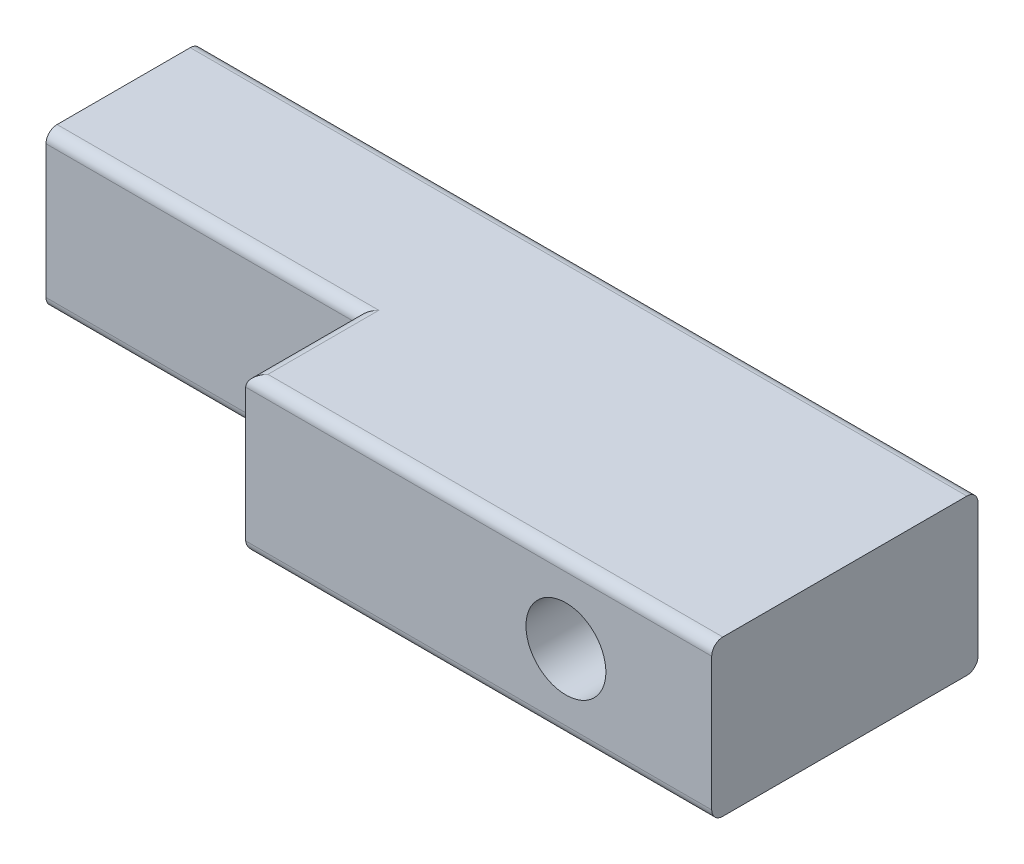
from build123d import *

# Parameters (mm, degrees)
SKETCH1_W                  = 35
SKETCH1_H                  = 7
BOSS_EXTRUDE1_DEPTH        = 7
SKETCH3_W                  = 21
SKETCH3_H                  = 7
BOSS_EXTRUDE3_DEPTH        = 5
FILLET1_R                  = 0.5
F_3_6_3_6_DIAMETER_HOLE1_D = 3.6


with BuildPart() as part:
    # Sketch1 → Boss-Extrude1 (new body)
    with BuildSketch(Plane.XY):
        Rectangle(SKETCH1_W, SKETCH1_H)
    extrude(amount=BOSS_EXTRUDE1_DEPTH)

    # Sketch3 → Boss-Extrude3 (add)
    with BuildSketch(Plane.XY.offset(7)):
        with Locations((7, 0)):
            Rectangle(SKETCH3_W, SKETCH3_H)
    extrude(amount=BOSS_EXTRUDE3_DEPTH)

    # Fillet1
    fillet1_edges = [part.edges().sort_by_distance(p)[0] for p in [
        (-10.5, 3.5, 7),
        (-3.5, 3.5, 9.5),
        (-3.5, -3.5, 9.5),
        (-10.5, -3.5, 7),
        (7, 3.5, 12),
        (7, -3.5, 12),
        (0, -3.5, 0),
        (0, 3.5, 0),
    ]]
    fillet(fillet1_edges, radius=FILLET1_R)

    # Ø3.6 (3.6) Diameter Hole1 (through all)
    with Locations(Plane(origin=(10.929593105, 0, 0), x_dir=(-1, 0, 0), z_dir=(0, 0, -1))):
        with Locations((0, 0)):
            Hole(F_3_6_3_6_DIAMETER_HOLE1_D / 2)


solid = part.part
